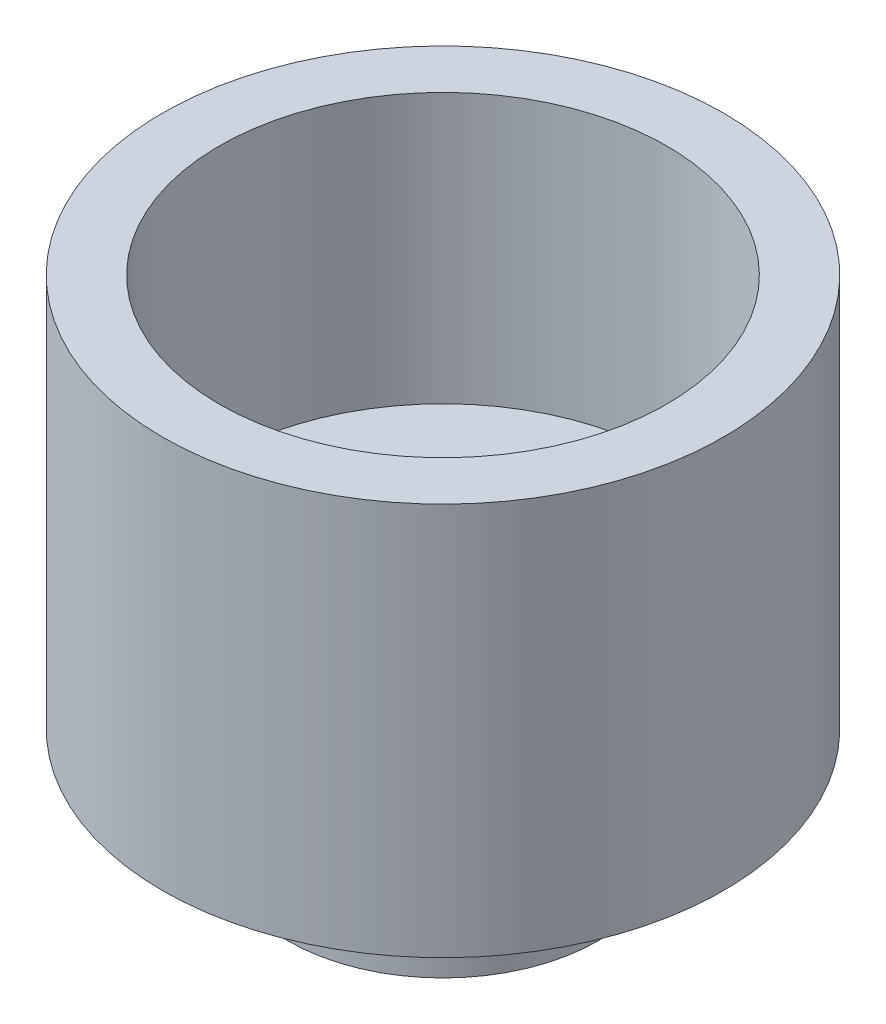
from build123d import *

# Parameters (mm, degrees)
ESQUISSE1_R             = 9.5
BOSS_EXTRU_2_DEPTH      = 13.3
ESQUISSE3_R             = 5.25
BOSS_EXTRU_3_DEPTH      = 3.6
ESQUISSE4_R             = 7.575
ENL_V_MAT_EXTRU_1_DEPTH = 9.13
ESQUISSE5_R             = 1.575
ENL_V_MAT_EXTRU_2_DEPTH = 9.13


with BuildPart() as part:
    # Esquisse1 → Boss.-Extru.2 (new body)
    with BuildSketch(Plane(origin=(0, 0, 0), x_dir=(1, 0, 0), z_dir=(0, 1, 0))):
        Circle(ESQUISSE1_R)
    extrude(amount=BOSS_EXTRU_2_DEPTH)

    # Esquisse3 → Boss.-Extru.3 (add)
    with BuildSketch(Plane.XZ):
        Circle(ESQUISSE3_R)
    extrude(amount=BOSS_EXTRU_3_DEPTH)

    # Esquisse4 → Enlèv. mat.-Extru.1 (cut)
    with BuildSketch(Plane(origin=(0, 13.3, 0), x_dir=(1, 0, 0), z_dir=(0, 1, 0))):
        Circle(ESQUISSE4_R)
    extrude(amount=-ENL_V_MAT_EXTRU_1_DEPTH, mode=Mode.SUBTRACT)

    # Esquisse5 → Enlèv. mat.-Extru.2 (cut)
    with BuildSketch(Plane.XZ.offset(3.6)):
        Circle(ESQUISSE5_R)
    extrude(amount=-ENL_V_MAT_EXTRU_2_DEPTH, mode=Mode.SUBTRACT)


solid = part.part
